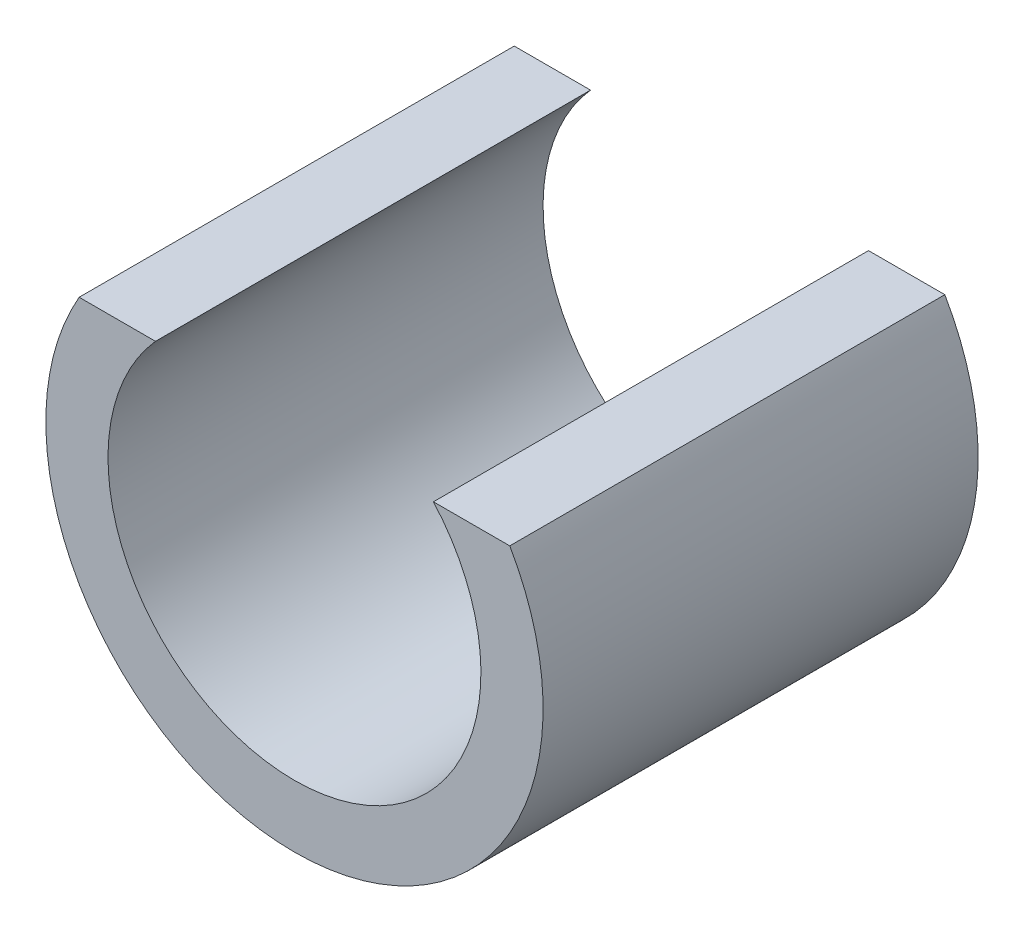
from build123d import *

# Parameters (mm, degrees)
EXTRUDE_1_DEPTH = 3.5


with BuildPart() as part:
    # 草图1 → 凸台-拉伸1 (new body)
    with BuildSketch(Plane.XY):
        with BuildLine():
            Line((-1.118033989, 1), (-1.732050808, 1))
            ThreePointArc((-1.732050808, 1), (-0.51763809, -1.931851653), (2, 0))
            ThreePointArc((2, 0), (1.931851653, 0.51763809), (1.732050808, 1))
            Line((1.732050808, 1), (1.118033989, 1))
            ThreePointArc((1.118033989, 1), (1.401258538, 0.535233135), (1.5, 0))
            ThreePointArc((1.5, 0), (-0.535233135, -1.401258538), (-1.118033989, 1))
        make_face()
    extrude(amount=EXTRUDE_1_DEPTH)


solid = part.part
